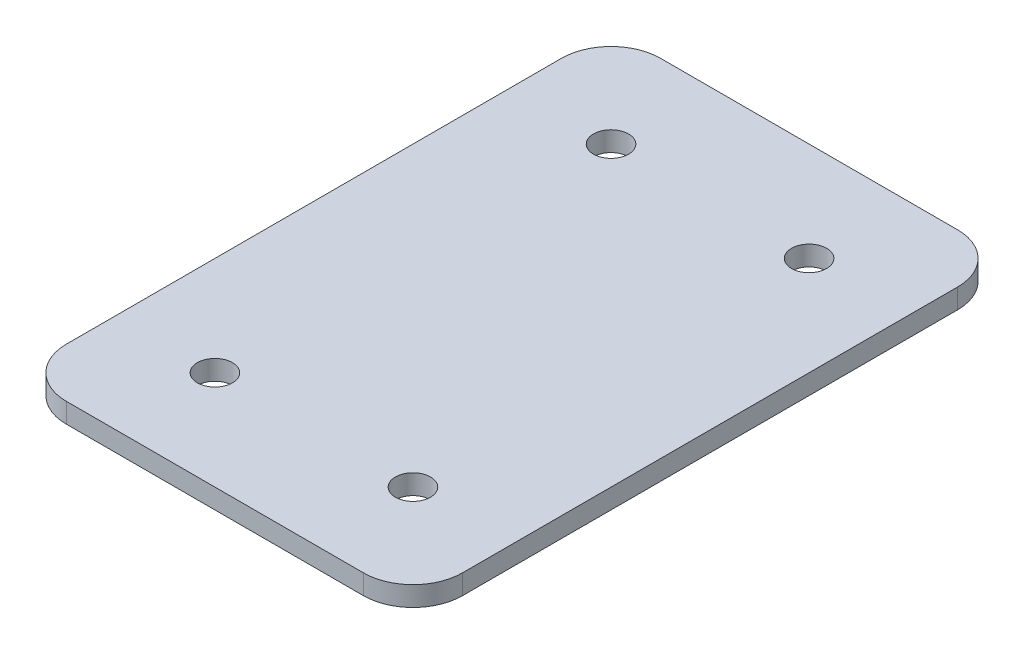
from build123d import *

# Parameters (mm, degrees)
SKETCH1_R           = 2.25
BOSS_EXTRUDE1_DEPTH = 2.54


with BuildPart() as part:
    # Sketch1 → Boss-Extrude1 (new body)
    with BuildSketch(Plane(origin=(0, 0, 0), x_dir=(1, 0, 0), z_dir=(0, 1, 0))):
        with BuildLine():
            Line((6.35, 0), (44.45, 0))
            ThreePointArc((44.45, 0), (48.940128061, 1.859871939), (50.8, 6.35))
            Line((50.8, 6.35), (50.8, 69.85))
            ThreePointArc((50.8, 69.85), (48.940128061, 74.340128061), (44.45, 76.2))
            Line((44.45, 76.2), (6.35, 76.2))
            ThreePointArc((6.35, 76.2), (1.859871939, 74.340128061), (0, 69.85))
            Line((0, 69.85), (0, 6.35))
            ThreePointArc((0, 6.35), (1.859871939, 1.859871939), (6.35, 0))
        make_face()
        with Locations((38.1, 12.7)):
            Circle(SKETCH1_R, mode=Mode.SUBTRACT)
        with Locations((12.7, 12.7)):
            Circle(SKETCH1_R, mode=Mode.SUBTRACT)
        with Locations((38.1, 63.5)):
            Circle(SKETCH1_R, mode=Mode.SUBTRACT)
        with Locations((12.7, 63.5)):
            Circle(SKETCH1_R, mode=Mode.SUBTRACT)
    extrude(amount=BOSS_EXTRUDE1_DEPTH)


solid = part.part
